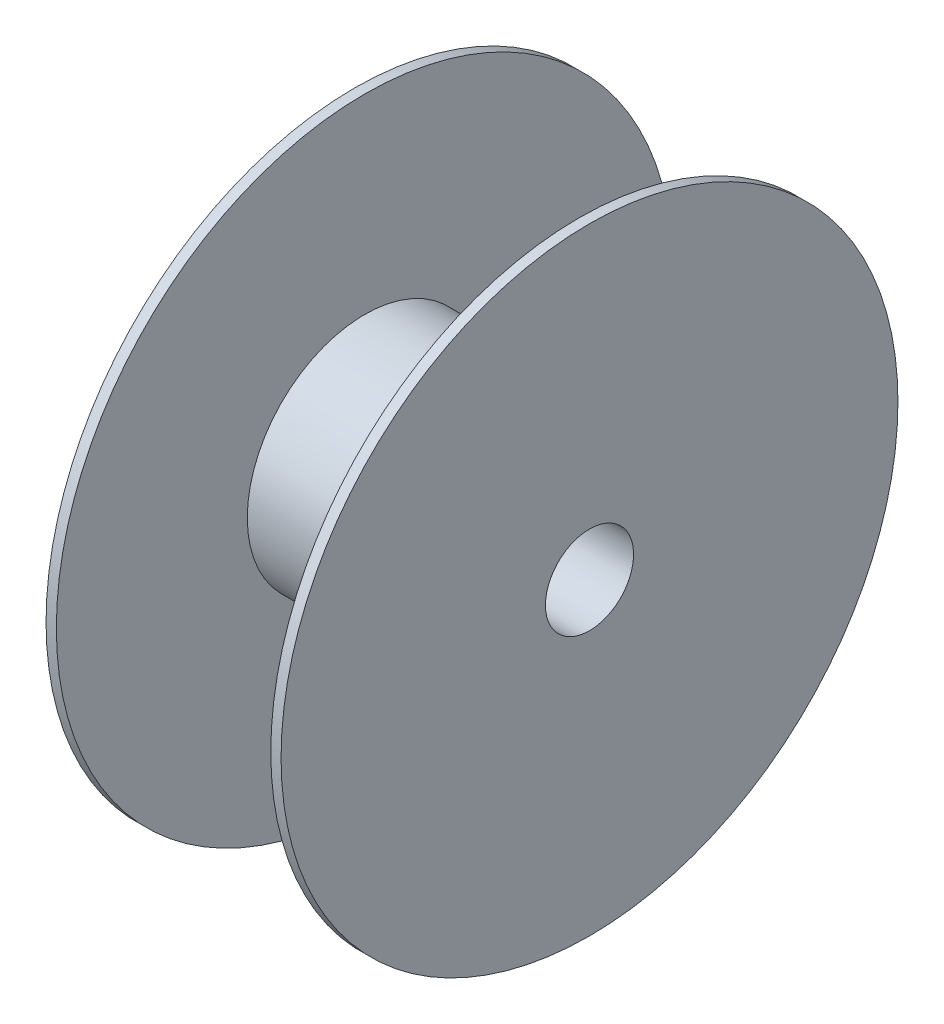
from build123d import *


with BuildPart() as part:
    # Sketch1 → Revolve1 (revolve)
    with BuildSketch(Plane.XY, mode=Mode.PRIVATE) as revolve1_sk:
        Polygon((101.6, 19.05), (0, 19.05), (0, 133.35), (4.445, 133.35), (4.445, 50.8), (97.155, 50.8), (97.155, 133.35), (101.6, 133.35), align=None)
    revolve(revolve1_sk.sketch.rotate(Axis((0, 0, 0), (1, 0, 0)), 90), axis=Axis((0, 0, 0), (1, 0, 0)))  # turned: the seam where the file's is


solid = part.part
